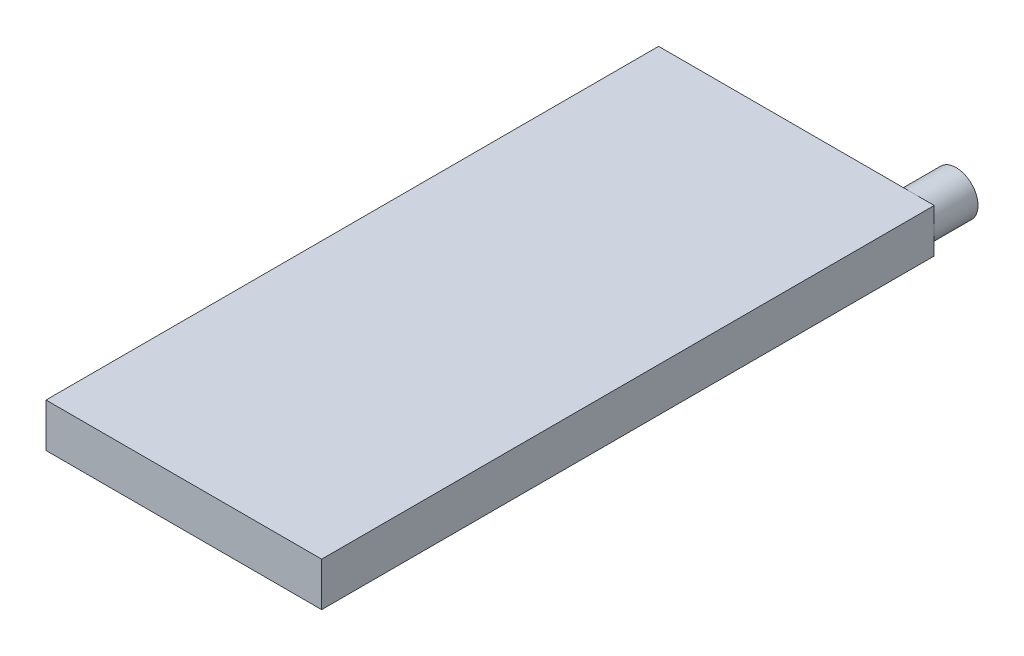
from build123d import *

# Parameters (mm, degrees)
ESQUISSE1_W        = 63
ESQUISSE1_H        = 140
BOSS_EXTRU_1_DEPTH = 10
ESQUISSE2_R        = 5
BOSS_EXTRU_2_DEPTH = 10


with BuildPart() as part:
    # Esquisse1 → Boss.-Extru.1 (new body)
    with BuildSketch(Plane(origin=(0, 0, 0), x_dir=(1, 0, 0), z_dir=(0, 1, 0))):
        with Locations((-31.5, 70)):
            Rectangle(ESQUISSE1_W, ESQUISSE1_H)
    extrude(amount=BOSS_EXTRU_1_DEPTH)

    # Esquisse2 → Boss.-Extru.2 (add)
    with BuildSketch(Plane(origin=(0, 0, -140), x_dir=(-1, 0, 0), z_dir=(0, 0, -1))):
        with Locations((5, 5)):
            Circle(ESQUISSE2_R)
    extrude(amount=BOSS_EXTRU_2_DEPTH)


solid = part.part
